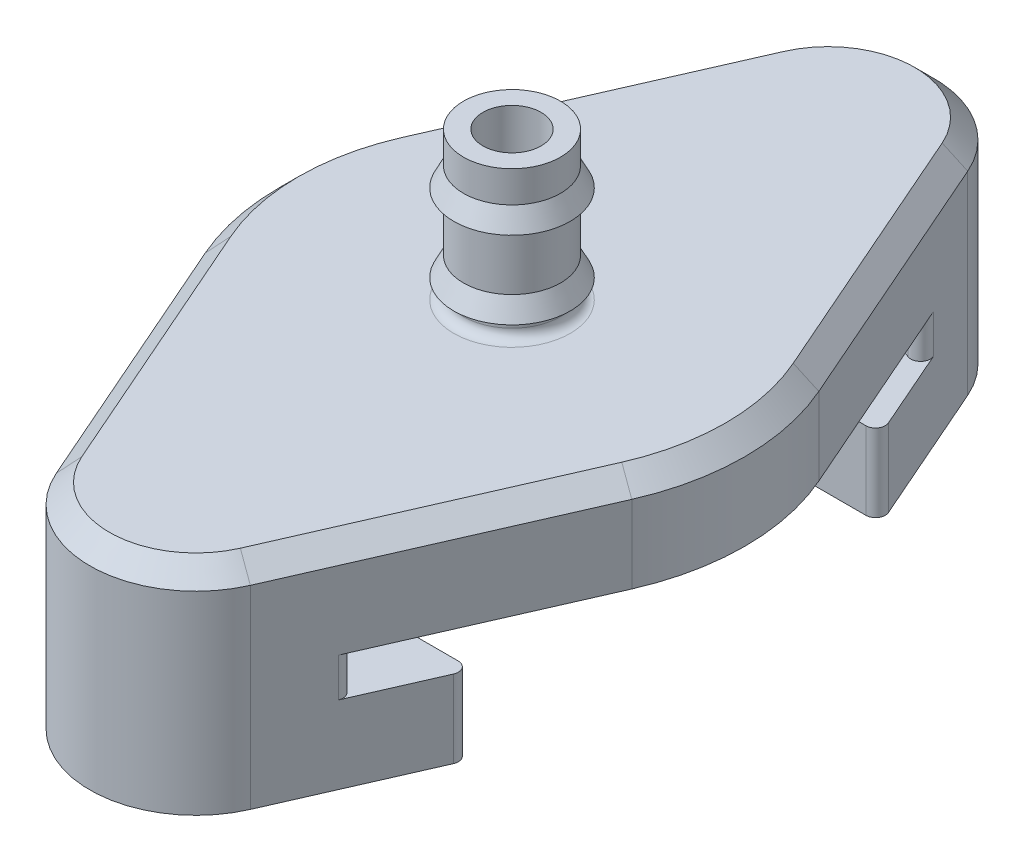
from build123d import *

# Parameters (mm, degrees)
CUT_EXTRUDE1_DEPTH  = 12
SKETCH5_W           = 24
SKETCH5_H           = 21
CUT_EXTRUDE3_DEPTH  = 6
FILLET1_R           = 0.5
FILLET3_R           = 0.5
CHAMFER2_SIZE       = 1
SKETCH12_R          = 1.4
CUT_EXTRUDE7_DEPTH  = 6
SKETCH13_R          = 7.375
CUT_EXTRUDE8_DEPTH  = 2
SKETCH14_R          = 7.375
SKETCH14_R_2        = 6.75
BOSS_EXTRUDE1_DEPTH = 1


with BuildPart() as part:
    # Sketch2 → Revolve1 (revolve)
    with BuildSketch(Plane(origin=(0, 0, 0), x_dir=(0, 0, -1), z_dir=(1, 0, 0))):
        Polygon((-2.5, 0), (-21.75, 0), (-21.75, -11), (-8.75, -11), (-8.75, -7), (-15.75, -7), (-15.75, -5), (-1.5, -5), (-1.5, 6), (-1.5, 7.616444111), (-2.5, 7.616444111), (-2.5, 6), (-3, 5), (-2.5, 5), (-2.5, 2), (-3, 1), (-2.5, 1), align=None)
    revolve(axis=Axis((0, 7.880012575, 0), (0, -1, 0)))

    # Sketch3 → Cut-Extrude1 (cut, through all)
    with BuildSketch(Plane(origin=(0, 0, 0), x_dir=(1, 0, 0), z_dir=(0, 1, 0))):
        with BuildLine():
            ThreePointArc((-10.990322793, -4.817966886), (-12, 0), (-10.990322793, 4.817966886))
            Line((-10.990322793, 4.817966886), (-5, 18.48256498))
            ThreePointArc((-5, 18.48256498), (-2.986475006, 20.860711972), (-2.4e-08, 21.75))
            ThreePointArc((-2.4e-08, 21.75), (-21.75, -1.1e-08), (-2e-09, -21.75))
            ThreePointArc((-2e-09, -21.75), (-2.986474997, -20.860711978), (-5, -18.48256498))
            Line((-5, -18.48256498), (-10.990322793, -4.817966886))
        make_face()
        with BuildLine():
            ThreePointArc((21.75, 0), (15.379572482, 15.379572499), (-2.4e-08, 21.75))
            ThreePointArc((-2.4e-08, 21.75), (2.986474986, 20.860711985), (5, 18.48256498))
            Line((5, 18.48256498), (10.990322793, 4.817966886))
            ThreePointArc((10.990322793, 4.817966886), (12, 0), (10.990322793, -4.817966886))
            Line((10.990322793, -4.817966886), (5, -18.48256498))
            ThreePointArc((5, -18.48256498), (2.986474995, -20.860711979), (-2e-09, -21.75))
            ThreePointArc((-2e-09, -21.75), (15.37957249, -15.379572492), (21.75, 0))
        make_face()
    extrude(amount=-CUT_EXTRUDE1_DEPTH, mode=Mode.SUBTRACT)

    # Sketch5 → Cut-Extrude3 (cut)
    with BuildSketch(Plane.XZ.offset(11)):
        Rectangle(SKETCH5_W, SKETCH5_H)
    extrude(amount=-CUT_EXTRUDE3_DEPTH, mode=Mode.SUBTRACT)

    # Fillet1
    fillet1_edges = [part.edges().sort_by_distance(p)[0] for p in [
        (8.49941803, -9, 10.5),
        (-8.49941803, -9, 10.5),
        (-8.49941803, -9, -10.5),
        (-6.894608136, -6, -14.160751345),
        (-6.894608136, -6, 14.160751345),
        (6.894608136, -6, -14.160751345),
        (6.894608136, -6, 14.160751345),
        (8.49941803, -9, -10.5),
    ]]
    fillet(fillet1_edges, radius=FILLET1_R)

    # Fillet3
    fillet3_edges = [part.edges().sort_by_distance(p)[0] for p in [
        (0, 0, -2.5),
    ]]
    fillet(fillet3_edges, radius=FILLET3_R)

    # Chamfer2
    chamfer2_edges = [part.edges().sort_by_distance(p)[0] for p in [
        (0, 0, 21.75),
        (-7.995161396, 0, 11.650265933),
        (-12, 0, 0),
        (-7.995161396, 0, -11.650265933),
        (0, 0, -21.75),
        (7.995161396, 0, 11.650265933),
        (7.995161396, 0, -11.650265933),
        (12, 0, 0),
    ]]
    chamfer(chamfer2_edges, length=CHAMFER2_SIZE)

    # Sketch12 → Cut-Extrude7 (cut)
    with BuildSketch(Plane.XZ.offset(11)):
        with Locations((0, -13.25)):
            Circle(SKETCH12_R)
        with Locations((0, 13.25)):
            Circle(SKETCH12_R)
    extrude(amount=-CUT_EXTRUDE7_DEPTH, mode=Mode.SUBTRACT)

    # Sketch13 → Cut-Extrude8 (cut)
    with BuildSketch(Plane.XZ.offset(5)):
        Circle(SKETCH13_R)
    extrude(amount=-CUT_EXTRUDE8_DEPTH, mode=Mode.SUBTRACT)


with BuildPart() as body_2:
    # Sketch14 → Boss-Extrude1 (new body)
    with BuildSketch(Plane.XZ.offset(5)):
        Circle(SKETCH14_R)
        Circle(SKETCH14_R_2, mode=Mode.SUBTRACT)
    extrude(amount=-BOSS_EXTRUDE1_DEPTH)


with BuildPart() as part_1:
    add(part.part)

    # Combine1: union body 2
    add(body_2.part)


solid = part_1.part
